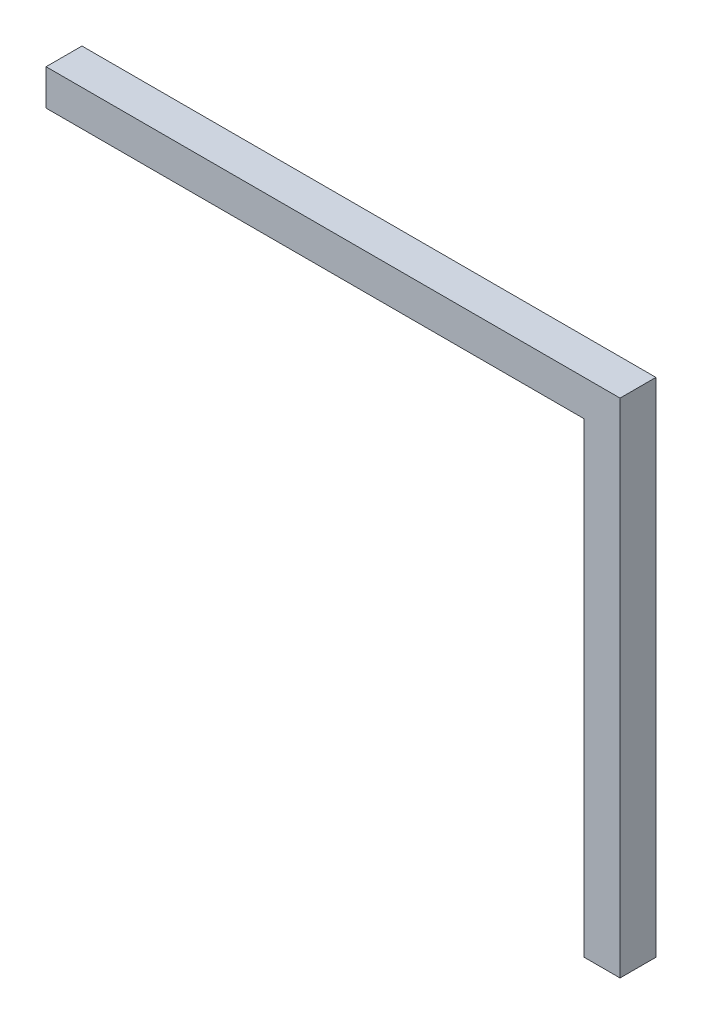
from build123d import *

# Parameters (mm, degrees)
BOSS_EXTRUDE1_DEPTH = 0.5


with BuildPart() as part:
    # Sketch1 → Boss-Extrude1 (new body)
    with BuildSketch(Plane.XY):
        Polygon((-5.7, 10.56264653), (-5.7, 17.06264653), (-13.2, 17.06264653), (-13.2, 17.56264653), (-5.2, 17.56264653), (-5.2, 10.56264653), align=None)
    extrude(amount=BOSS_EXTRUDE1_DEPTH)


solid = part.part
